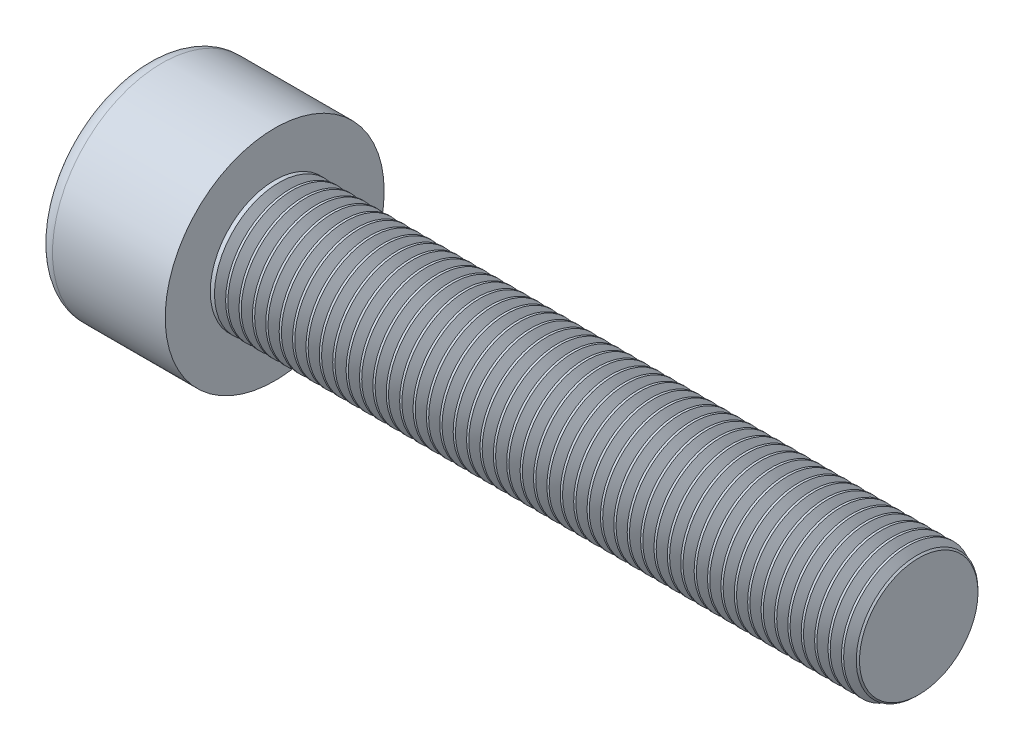
from build123d import *

# Parameters (mm, degrees)
SKETCH1_R           = 4.25
BASEHEAD_DEPTH      = 5
SKETCH2_R           = 2.5
BASEBODY_DEPTH      = 25
HEXAGONSOCKET_DEPTH = 2.5
TOPFILLET_R         = 0.625
CHAMFER1_SIZE       = 0.2
LPATTERN10_COUNT    = 48
LPATTERN10_PITCH    = 0.5196


with BuildPart() as part:
    # Sketch1 → BaseHead (new body)
    with BuildSketch(Plane(origin=(0, 0, 0), x_dir=(0, 0, -1), z_dir=(1, 0, 0))):
        Circle(SKETCH1_R)
    extrude(amount=BASEHEAD_DEPTH)

    # Sketch2 → BaseBody (add)
    with BuildSketch(Plane(origin=(5, 0, 0), x_dir=(0, 0, -1), z_dir=(1, 0, 0))):
        Circle(SKETCH2_R)
    extrude(amount=BASEBODY_DEPTH)

    # Sketch3 → HexagonSocket (cut)
    with BuildSketch(Plane(origin=(0, 0, 0), x_dir=(0, 0, -1), z_dir=(1, 0, 0))):
        Polygon((2.309401077, 0), (1.154700538, 2), (-1.154700538, 2), (-2.309401077, 0), (-1.154700538, -2), (1.154700538, -2), align=None)
    extrude(amount=HEXAGONSOCKET_DEPTH, mode=Mode.SUBTRACT)

    # Sketch4 → Cut-Revolve1 (revolve, cut)
    with BuildSketch(Plane(origin=(-4.19613823, 0.75, 0), x_dir=(-1, 0, 0), z_dir=(0, 0, 1))):
        Polygon((-6.69613823, 2.75), (-7.850838768, 0.75), (-6.69613823, 0.75), align=None)
    revolve(axis=Axis((0.838992387, 0, 0), (-1, 0, 0)), mode=Mode.SUBTRACT)

    # TopFillet
    topfillet_edges = [part.edges().sort_by_distance(p)[0] for p in [
        (0, 0, 4.25),
    ]]
    fillet(topfillet_edges, radius=TOPFILLET_R)

    # Chamfer1
    chamfer1_edges = [part.edges().sort_by_distance(p)[0] for p in [
        (30, 0, 2.5),
    ]]
    chamfer(chamfer1_edges, length=CHAMFER1_SIZE)

    # Sketch5 → Cut-Revolve10 (revolve, cut)
    with BuildSketch(Plane.XY):
        Polygon((29.8, 2.125011), (30.0165, 2.5), (30.0165, 2.933), (29.5835, 2.933), (29.5835, 2.5), align=None)
    cut_revolve10 = revolve(axis=Axis((0, 0, 0), (1, 0, 0)), mode=Mode.SUBTRACT)

    # LPattern10: Cut-Revolve10 ×48
    with Locations(*[(-i * LPATTERN10_PITCH, 0, 0) for i in range(1, LPATTERN10_COUNT)]):
        add(cut_revolve10, mode=Mode.SUBTRACT)


solid = part.part
